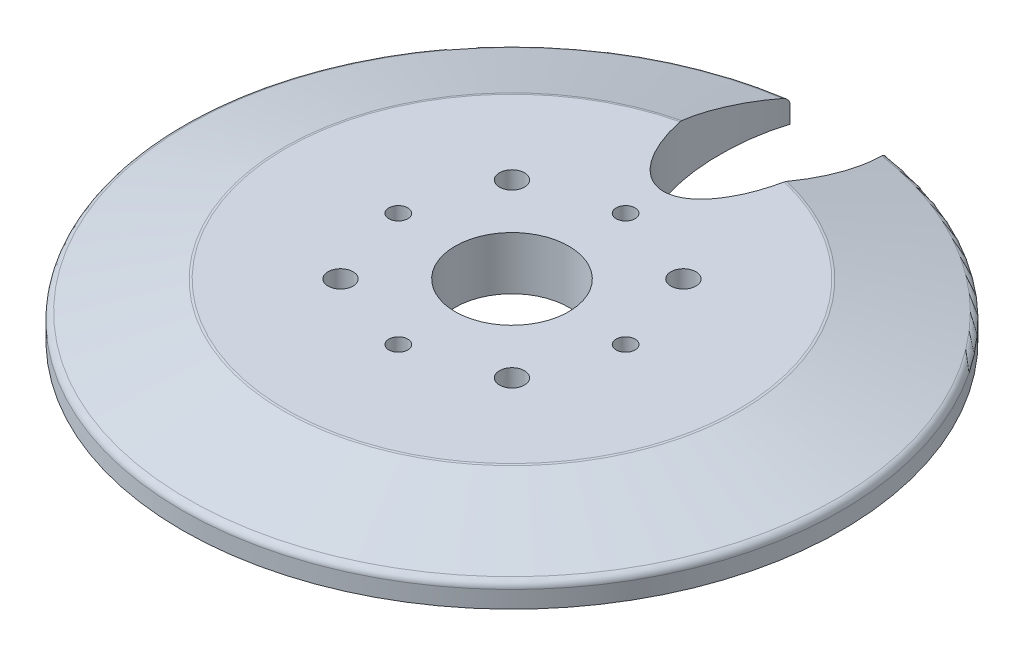
from build123d import *

# Parameters (mm, degrees)
SKETCH_2_R          = 7.5
CUT_EXTRUDE_1_DEPTH = 8
SKETCH_3_RX         = 15
SKETCH_3_RY         = 7.5
CUT_EXTRUDE_2_DEPTH = 8
M3X0_51_D           = 2.5
M4X0_71_D           = 3.3
FILLET_1_R          = 1


with BuildPart() as part:
    # Эскиз1 → Повернуть1 (revolve)
    with BuildSketch(Plane.XY):
        Polygon((0, 0), (-43.5, 0), (-43.5, 3), (-30, 7), (0, 7), align=None)
    revolve(axis=Axis((0, 7, 0), (0, -1, 0)))

    # Эскиз2 → Вырез-Вытянуть1 (cut, through all)
    with BuildSketch(Plane(origin=(0, 7, 0), x_dir=(1, 0, 0), z_dir=(0, 1, 0))):
        Circle(SKETCH_2_R)
    extrude(amount=-CUT_EXTRUDE_1_DEPTH, mode=Mode.SUBTRACT)

    # Эскиз3 → Вырез-Вытянуть2 (cut, through all)
    with BuildSketch(Plane(origin=(0, 7, 0), x_dir=(1, 0, 0), z_dir=(0, 1, 0))):
        with Locations(Location((0, 35), (0, 0, -90))):
            Ellipse(SKETCH_3_RX, SKETCH_3_RY)
    extrude(amount=-CUT_EXTRUDE_2_DEPTH, mode=Mode.SUBTRACT)

    # Отверстие обработанное метчиком M3x0.51 (through all)
    with Locations(Plane(origin=(0, 7, 0), x_dir=(1, 0, 0), z_dir=(0, 1, 0))):
        with Locations((0, 15), (-15, 0), (0, -15), (15, 0)):
            Hole(M3X0_51_D / 2)

    # Отверстие обработанное метчиком M4x0.71 (through all)
    with Locations(Plane(origin=(0, 7, 0), x_dir=(1, 0, 0), z_dir=(0, 1, 0))):
        with Locations((-11.313708499, 11.313708499), (11.313708499, 11.313708499), (11.313708499, -11.313708499), (-11.313708499, -11.313708499)):
            Hole(M4X0_71_D / 2)

    # Скругление1
    fillet_1_edges = [part.edges().sort_by_distance(p)[0] for p in [
        (0, 7, 30),
        (0, 3, 43.5),
    ]]
    fillet(fillet_1_edges, radius=FILLET_1_R)


solid = part.part
